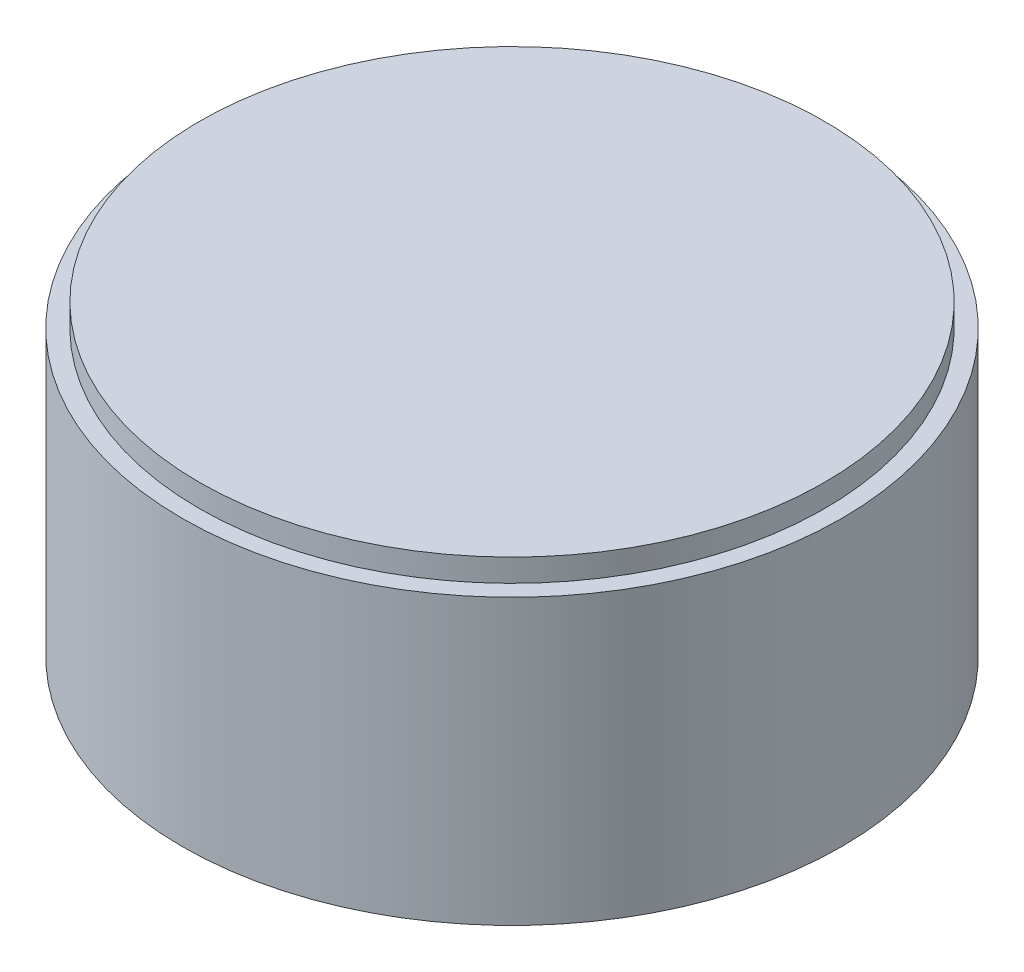
from build123d import *

# Parameters (mm, degrees)
SKETCH1_R           = 5.8
BOSS_EXTRUDE1_DEPTH = 5
SKETCH2_R           = 5.5
BOSS_EXTRUDE2_DEPTH = 0.4


with BuildPart() as part:
    # Sketch1 → Boss-Extrude1 (new body)
    with BuildSketch(Plane(origin=(0, 0, 0), x_dir=(1, 0, 0), z_dir=(0, 1, 0))):
        Circle(SKETCH1_R)
    extrude(amount=BOSS_EXTRUDE1_DEPTH)

    # Sketch2 → Boss-Extrude2 (add)
    with BuildSketch(Plane(origin=(0, 5, 0), x_dir=(1, 0, 0), z_dir=(0, 1, 0))):
        Circle(SKETCH2_R)
    extrude(amount=BOSS_EXTRUDE2_DEPTH)


solid = part.part
